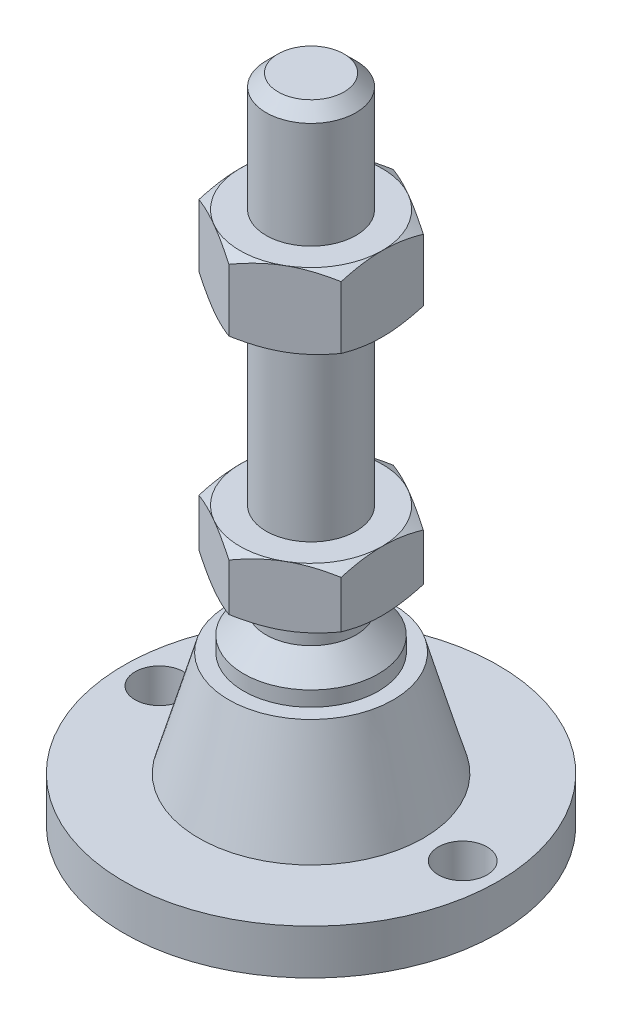
from build123d import *

# Parameters (mm, degrees)
EXTRUDE_1_DEPTH     = 8
EXTRUDE_2_DEPTH     = 10
SKETCH_5_R          = 3.25
CUT_EXTRUDE_1_DEPTH = 7


with BuildPart() as part:
    # Эскиз1 → Повернуть1 (revolve)
    with BuildSketch(Plane.XY, mode=Mode.PRIVATE) as revolve_1_sk:
        Polygon((0, 0), (-25, 0), (-25, 6), (-15, 6), (-11, 20), (-9, 20), (-9, 22), (-6, 25), (-6, 29), (-6, 37), (-6, 85.4), (-4.4, 87), (0, 87), align=None)
    revolve(revolve_1_sk.sketch.rotate(Axis((0, 0, 0), (0, 1, 0)), 180), axis=Axis((0, 0, 0), (0, 1, 0)))  # turned: the seam where the file's is

    # Эскиз2 → Бобышка-Вытянуть1 (add)
    with BuildSketch(Plane(origin=(0, 29, 0), x_dir=(1, 0, 0), z_dir=(0, 1, 0))):
        Polygon((0, 10.969655115), (-9.5, 5.484827557), (-9.5, -5.484827557), (0, -10.969655115), (9.5, -5.484827557), (9.5, 5.484827557), align=None)
    extrude(amount=EXTRUDE_1_DEPTH)

    # Эскиз3 → Бобышка-Вытянуть2 (add)
    with BuildSketch(Plane(origin=(0, 61.2, 0), x_dir=(1, 0, 0), z_dir=(0, 1, 0))):
        Polygon((9.5, 5.484827557), (0, 10.969655115), (-9.5, 5.484827557), (-9.5, -5.484827557), (0, -10.969655115), (9.5, -5.484827557), align=None)
    extrude(amount=EXTRUDE_2_DEPTH)

    # Эскиз4 → Вырез-Повернуть2 (revolve, cut)
    with BuildSketch(Plane.XY, mode=Mode.PRIVATE) as cut_revolve_2_sk:
        Polygon((-18.160254038, 71.2), (-9.5, 71.2), (-18.160254038, 66.2), align=None)
        Polygon((-18.160254038, 61.2), (-18.160254038, 66.2), (-9.5, 61.2), align=None)
        Polygon((-16.42820323, 37), (-16.42820323, 33), (-9.5, 37), align=None)
        Polygon((-16.42820323, 33), (-16.42820323, 29), (-9.5, 29), align=None)
    revolve(cut_revolve_2_sk.sketch.rotate(Axis((0, 87, 0), (0, 1, 0)), 180), axis=Axis((0, 87, 0), (0, 1, 0)), mode=Mode.SUBTRACT)  # turned: the seam where the file's is

    # Эскиз5 → Вырез-Вытянуть1 (cut, through all)
    with BuildSketch(Plane(origin=(0, 6, 0), x_dir=(1, 0, 0), z_dir=(0, 1, 0))):
        with Locations(Location((-20.25, 0, 0), (0, 0, 180))):  # turned: the seam where the file's is
            Circle(SKETCH_5_R)
        with Locations(Location((20.25, 0, 0), (0, 0, 180))):  # turned: the seam where the file's is
            Circle(SKETCH_5_R)
    extrude(amount=-CUT_EXTRUDE_1_DEPTH, mode=Mode.SUBTRACT)


solid = part.part
